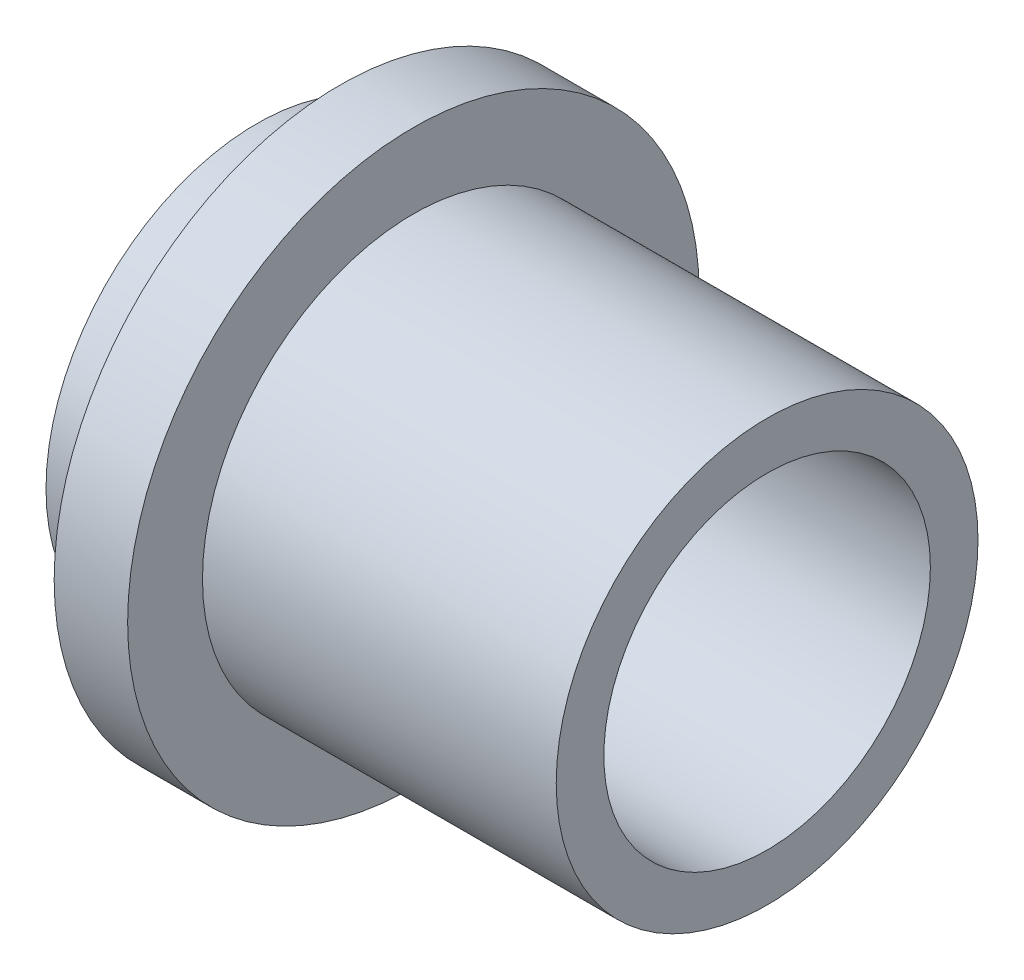
from build123d import *

# Parameters (mm, degrees)
F_1_4_0_24_DIAMETER_HOLE1_D = 6.096


with BuildPart() as part:
    # Sketch1 → Revolve1 (revolve)
    with BuildSketch(Plane.XY):
        Polygon((0, 0), (0, 3.937), (0.635, 3.937), (1.5494, 4.8514), (1.5494, 5.334), (2.921, 5.334), (2.921, 3.937), (9.525, 3.937), (9.525, 0), align=None)
    revolve(axis=Axis((-1.987928477, 0, 0), (1, 0, 0)))

    # 1/4 (0.24) Diameter Hole1 (through all)
    with Locations(Plane(origin=(9.525, 0, 0), x_dir=(0, 0, -1), z_dir=(1, 0, 0))):
        with Locations((0, 0)):
            Hole(F_1_4_0_24_DIAMETER_HOLE1_D / 2)


solid = part.part
